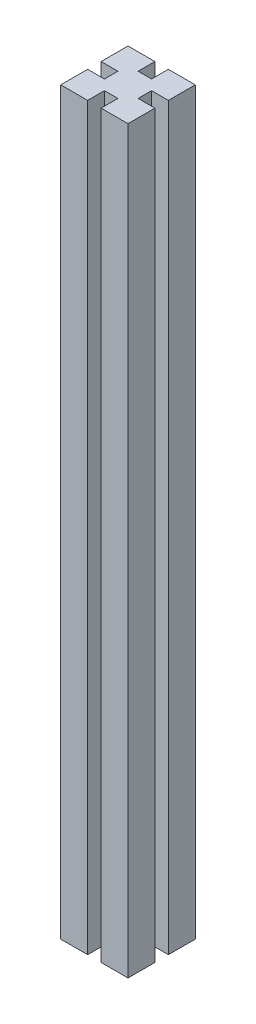
from build123d import *

# Parameters (mm, degrees)
BOSS_EXTRUDE1_DEPTH = 550
BOSS_EXTRUDE2_DEPTH = 10


with BuildPart() as part:
    # Sketch1 → Boss-Extrude1 (new body)
    with BuildSketch(Plane(origin=(0, 0, 0), x_dir=(1, 0, 0), z_dir=(0, 1, 0))):
        Polygon((-25, 25), (-5, 25), (-5, 12.5), (5, 12.5), (5, 25), (25, 25), (25, 5), (12.5, 5), (12.5, -5), (25, -5), (25, -25), (5, -25), (5, -12.5), (-5, -12.5), (-5, -25), (-25, -25), (-25, -5), (-12.5, -5), (-12.5, 5), (-25, 5), align=None)
    extrude(amount=BOSS_EXTRUDE1_DEPTH)

    # Sketch1_2 → Boss-Extrude2 (add)
    with BuildSketch(Plane(origin=(0, 0, 0), x_dir=(1, 0, 0), z_dir=(0, 1, 0))):
        Polygon((-25, 25), (-5, 25), (-5, 12.5), (5, 12.5), (5, 25), (25, 25), (25, 5), (12.5, 5), (12.5, -5), (25, -5), (25, -25), (5, -25), (5, -12.5), (-5, -12.5), (-5, -25), (-25, -25), (-25, -5), (-12.5, -5), (-12.5, 5), (-25, 5), align=None)
    extrude(amount=BOSS_EXTRUDE2_DEPTH)


solid = part.part
